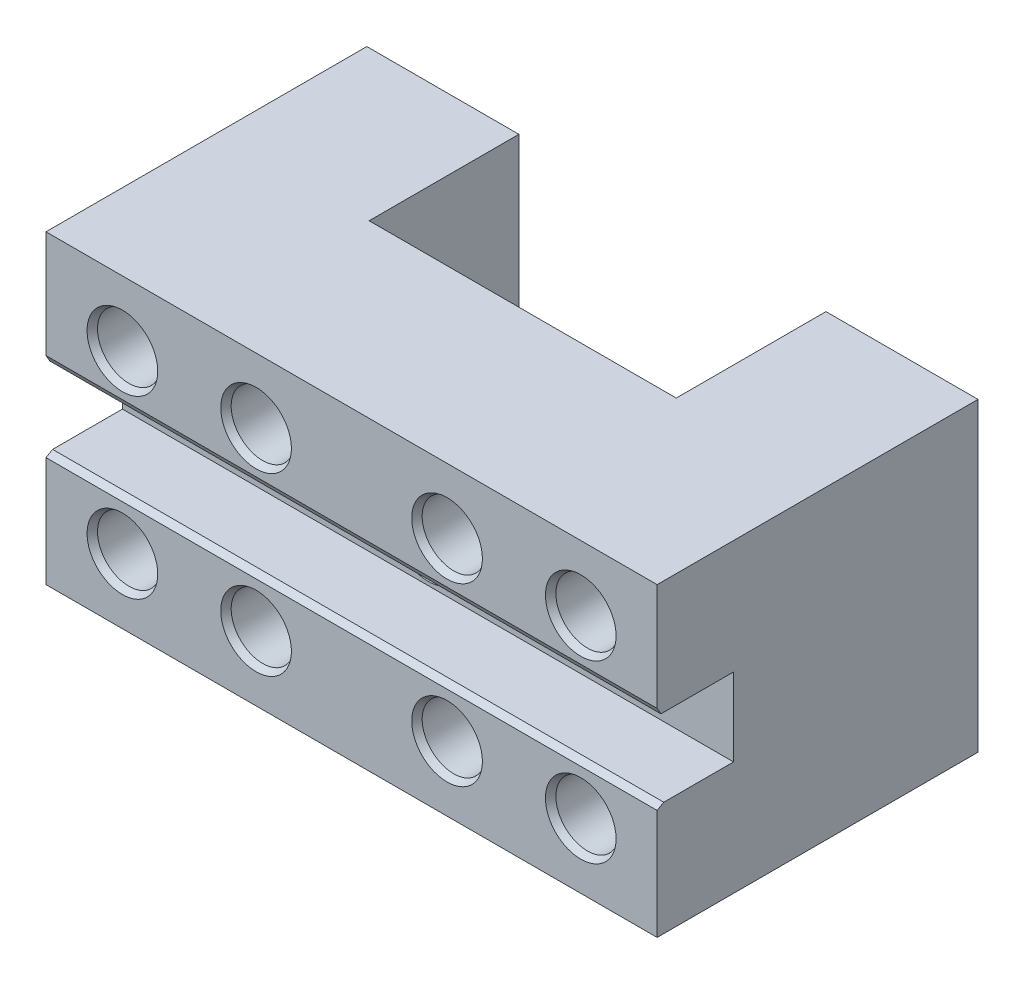
from build123d import *

# Parameters (mm, degrees)
BOSS_EXTRUDE2_DEPTH   = 40
BOSS_EXTRUDE3_DEPTH   = 80
SKETCH5_R             = 4.125
CUT_EXTRUDE1_DEPTH    = 43
CHAMFER1_SIZE         = 0.5
CHAMFER1_SIZE2        = 0.866025404
CHAMFER1_PART_2_SIZE  = 0.5
CHAMFER1_PART_2_SIZE2 = 0.866025404
CHAMFER1_PART_3_SIZE  = 0.5
CHAMFER1_PART_3_SIZE2 = 0.866025404
CHAMFER1_PART_4_SIZE  = 0.5
CHAMFER1_PART_4_SIZE2 = 0.866025404


with BuildPart() as part:
    # Sketch2 → Boss-Extrude2 (new body)
    with BuildSketch(Plane(origin=(0, 0, 0), x_dir=(1, 0, 0), z_dir=(0, 1, 0))):
        Polygon((-31.312103746, 30), (-31.312103746, 0), (48.687896254, 0), (48.687896254, 30), (28.787896254, 30), (28.787896254, 10.4), (-11.412103746, 10.4), (-11.412103746, 30), align=None)
    extrude(amount=BOSS_EXTRUDE2_DEPTH)

    # Sketch4 → Boss-Extrude3 (add)
    with BuildSketch(Plane(origin=(48.687896254, 0, 0), x_dir=(0, 0, -1), z_dir=(1, 0, 0))):
        Polygon((0, 0), (-12, 0), (-12, 14.9), (-2, 14.9), (-2, 25.1), (-12, 25.1), (-12, 40), (0, 40), align=None)
    extrude(amount=-BOSS_EXTRUDE3_DEPTH)

    # Sketch5 → Cut-Extrude1 (cut, through all)
    with BuildSketch(Plane.XY.offset(12)):
        with Locations((-3.812103746, 31.5)):
            Circle(SKETCH5_R)
        with Locations((21.187896254, 31.5)):
            Circle(SKETCH5_R)
        with Locations((21.187896254, 8.5)):
            Circle(SKETCH5_R)
        with Locations((-3.812103746, 8.5)):
            Circle(SKETCH5_R)
        with Locations((-21.312103746, 31.5)):
            Circle(SKETCH5_R)
        with Locations((-21.312103746, 8.5)):
            Circle(SKETCH5_R)
        with Locations((38.687896254, 8.5)):
            Circle(SKETCH5_R)
        with Locations((38.687896254, 31.5)):
            Circle(SKETCH5_R)
        with Locations((8.687896254, 20)):
            Circle(SKETCH5_R)
    extrude(amount=-CUT_EXTRUDE1_DEPTH, mode=Mode.SUBTRACT)

    # Chamfer1
    chamfer1_edges = [part.edges().sort_by_distance(p)[0] for p in [
        (8.687896254, 14.9, 12),
        (34.562896254, 8.5, 12),
        (-25.437103746, 8.5, 12),
        (-7.937103746, 8.5, 12),
        (17.062896254, 8.5, 12),
    ]]
    chamfer1_side = [part.faces().sort_by_distance(p)[0] for p in [
        (8.687896254, 7.220474811, 12),
    ]]
    chamfer(chamfer1_edges, length=CHAMFER1_SIZE, length2=CHAMFER1_SIZE2, reference=chamfer1_side[0])

    # Chamfer1 part 2
    chamfer1_part_2_edges = [part.edges().sort_by_distance(p)[0] for p in [
        (8.687896254, 25.1, 12),
    ]]
    chamfer1_part_2_side = [part.faces().sort_by_distance(p)[0] for p in [
        (8.687896254, 25.1, 7),
    ]]
    chamfer(chamfer1_part_2_edges, length=CHAMFER1_PART_2_SIZE, length2=CHAMFER1_PART_2_SIZE2, reference=chamfer1_part_2_side[0])

    # Chamfer1 part 3
    chamfer1_part_3_edges = [part.edges().sort_by_distance(p)[0] for p in [
        (-7.937103746, 31.5, 12),
        (34.562896254, 31.5, 12),
        (-25.437103746, 31.5, 12),
        (17.062896254, 31.5, 12),
    ]]
    chamfer1_part_3_side = [part.faces().sort_by_distance(p)[0] for p in [
        (8.687896254, 32.779525189, 12),
    ]]
    chamfer(chamfer1_part_3_edges, length=CHAMFER1_PART_3_SIZE, length2=CHAMFER1_PART_3_SIZE2, reference=chamfer1_part_3_side[0])

    # Chamfer1 part 4
    chamfer1_part_4_edges = [part.edges().sort_by_distance(p)[0] for p in [
        (4.562896254, 20, 2),
    ]]
    chamfer1_part_4_side = [part.faces().sort_by_distance(p)[0] for p in [
        (8.687896254, 15.706476286, 2),
    ]]
    chamfer(chamfer1_part_4_edges, length=CHAMFER1_PART_4_SIZE, length2=CHAMFER1_PART_4_SIZE2, reference=chamfer1_part_4_side[0])


solid = part.part
